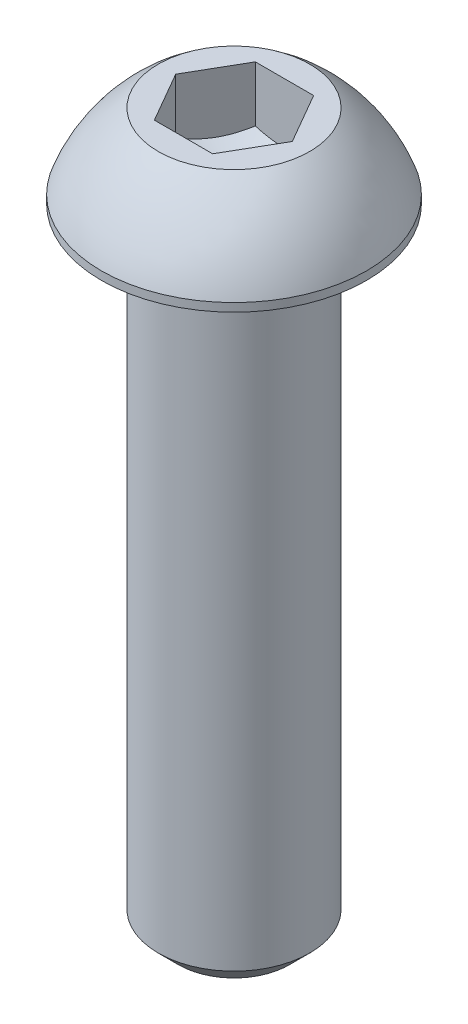
from build123d import *

# Parameters (mm, degrees)
Y_KSEKLIK_EKSTR_ZYON1_START = -2.378633
IZIM2_R                     = 3
Y_KSEKLIK_EKSTR_ZYON1_DEPTH = 2.378633


with BuildPart() as part:
    # Çizim1 → Döndür1 (revolve)
    with BuildSketch(Plane.XY):
        with BuildLine():
            Line((2.309401077, 0), (3, 0))
            ThreePointArc((3, 0), (4.355337259, -1.310502077), (5.25, -2.97))
            Line((5.25, -2.97), (5.25, -3.3))
            Line((5.25, -3.3), (3.25, -3.3))
            ThreePointArc((3.25, -3.3), (3.426776695, -2.873223305), (3, -3.05))
            Line((3, -3.05), (3, -27.5))
            Line((3, -27.5), (2.2, -28.3))
            Line((2.2, -28.3), (0, -28.3))
            Line((0, -28.3), (0, -3.533333333))
            Line((0, -3.533333333), (2.309401077, -2.2))
            Line((2.309401077, -2.2), (2.309401077, 0))
        make_face()
    revolve(axis=Axis((0, -3.533333333, 0), (0, -1, 0)))

    # Çizim2 → Yükseklik-Ekstrüzyon1 (add)
    with BuildSketch(Plane(origin=(0, 0, 0), x_dir=(1, 0, 0), z_dir=(0, 1, 0)).offset(Y_KSEKLIK_EKSTR_ZYON1_START)):
        Circle(IZIM2_R)
        Polygon((2.309401077, 0), (1.154700538, 2), (-1.154700538, 2), (-2.309401077, 0), (-1.154700538, -2), (1.154700538, -2), align=None, mode=Mode.SUBTRACT)
    extrude(amount=Y_KSEKLIK_EKSTR_ZYON1_DEPTH)


solid = part.part
